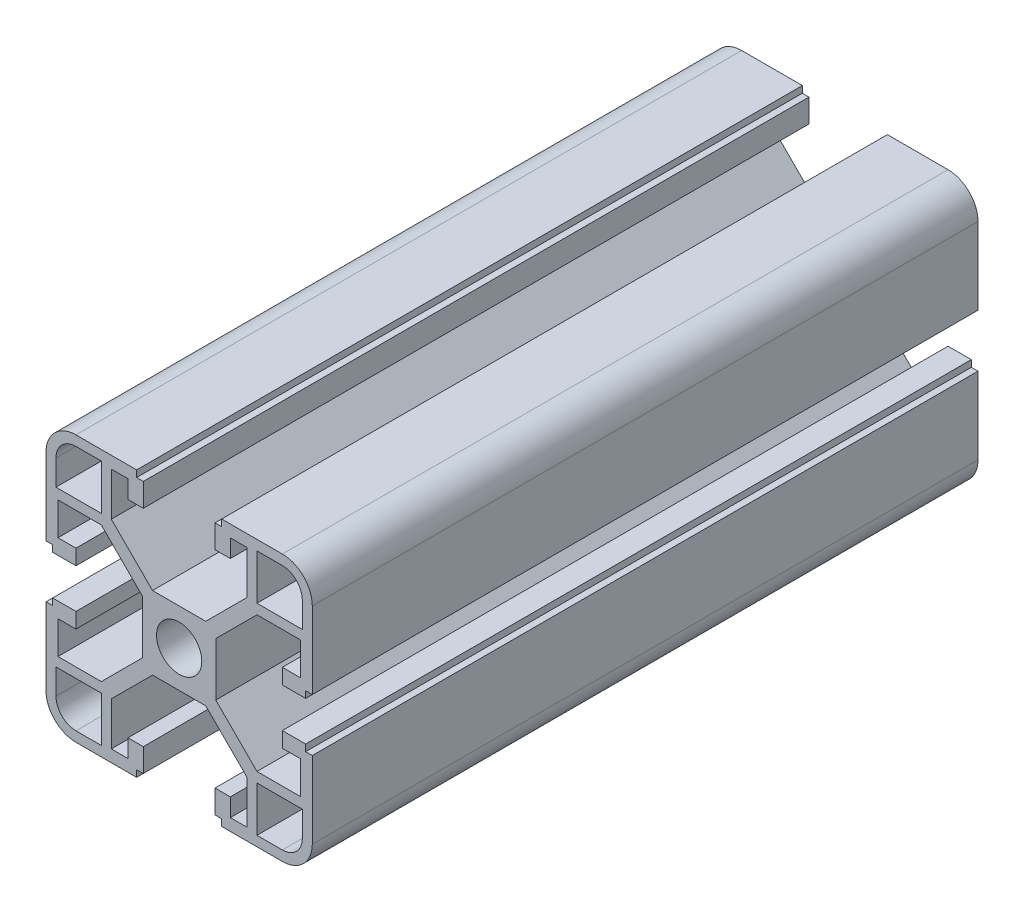
from build123d import *

# Parameters (mm, degrees)
BOSS_EXTRUDE1_DEPTH  = 100
MIRROR3_COPY_1_DEPTH = 100
MIRROR3_COPY_2_DEPTH = 100


with BuildPart() as part:
    # Sketch1 → Boss-Extrude1 (new body)
    with BuildSketch(Plane.XY):
        with BuildLine():
            Line((3.4, 0), (5.5, 0))
            Line((5.5, 0), (5.5, 4))
            Line((5.5, 4), (11.69, 10.19))
            Line((11.69, 10.19), (18.2, 10.19))
            Line((18.2, 10.19), (18.2, 5.265595036))
            Line((18.2, 5.265595036), (15.5, 5.265595036))
            Line((15.5, 5.265595036), (15.5, 2.965595036))
            Line((15.5, 2.965595036), (19, 2.965595036))
            Line((19, 2.965595036), (19, 3.965595036))
            Line((19, 3.965595036), (20, 3.965595036))
            Line((20, 3.965595036), (20, 15.5))
            ThreePointArc((20, 15.5), (18.681980515, 18.681980515), (15.5, 20))
            Line((15.5, 20), (6.385304712, 20))
            Line((6.385304712, 20), (6.385304712, 19))
            Line((6.385304712, 19), (5.385304712, 19))
            Line((5.385304712, 19), (5.385304712, 15.5))
            Line((5.385304712, 15.5), (7.685304712, 15.5))
            Line((7.685304712, 15.5), (7.685304712, 18.2))
            Line((7.685304712, 18.2), (10.19, 18.2))
            Line((10.19, 18.2), (10.19, 11.69))
            Line((10.19, 11.69), (4, 5.5))
            Line((4, 5.5), (0, 5.5))
            Line((0, 5.5), (0, 3.4))
            ThreePointArc((0, 3.4), (2.404163056, 2.404163056), (3.4, 0))
        make_face()
        with BuildLine():
            Line((18.5, 11.69), (18.5, 15.5))
            ThreePointArc((18.5, 15.5), (17.621320344, 17.621320344), (15.5, 18.5))
            Line((15.5, 18.5), (11.69, 18.5))
            Line((11.69, 18.5), (11.69, 11.69))
            Line((11.69, 11.69), (18.5, 11.69))
        make_face(mode=Mode.SUBTRACT)
    boss_extrude1 = extrude(amount=BOSS_EXTRUDE1_DEPTH)

    # Mirror1: Boss-Extrude1 across plane
    add(boss_extrude1.mirror(Plane.ZX))

    # Mirror2: Boss-Extrude1 across plane
    add(boss_extrude1.mirror(Plane(origin=(0, 0, 0), x_dir=(0, 0, 1), z_dir=(1, 0, 0))))

    # Mirror3 copy 1 sketch → Mirror3 copy 1 (add)
    with BuildSketch(Plane(origin=(0, 0, 0), x_dir=(-1, 0, 0), z_dir=(0, 0, 1))):
        with BuildLine():
            Line((3.4, 0), (5.5, 0))
            Line((5.5, 0), (5.5, 4))
            Line((5.5, 4), (11.69, 10.19))
            Line((11.69, 10.19), (18.2, 10.19))
            Line((18.2, 10.19), (18.2, 5.265595036))
            Line((18.2, 5.265595036), (15.5, 5.265595036))
            Line((15.5, 5.265595036), (15.5, 2.965595036))
            Line((15.5, 2.965595036), (19, 2.965595036))
            Line((19, 2.965595036), (19, 3.965595036))
            Line((19, 3.965595036), (20, 3.965595036))
            Line((20, 3.965595036), (20, 15.5))
            ThreePointArc((20, 15.5), (18.681980515, 18.681980515), (15.5, 20))
            Line((15.5, 20), (6.385304712, 20))
            Line((6.385304712, 20), (6.385304712, 19))
            Line((6.385304712, 19), (5.385304712, 19))
            Line((5.385304712, 19), (5.385304712, 15.5))
            Line((5.385304712, 15.5), (7.685304712, 15.5))
            Line((7.685304712, 15.5), (7.685304712, 18.2))
            Line((7.685304712, 18.2), (10.19, 18.2))
            Line((10.19, 18.2), (10.19, 11.69))
            Line((10.19, 11.69), (4, 5.5))
            Line((4, 5.5), (0, 5.5))
            Line((0, 5.5), (0, 3.4))
            ThreePointArc((0, 3.4), (2.404163056, 2.404163056), (3.4, 0))
        make_face()
        with BuildLine():
            Line((18.5, 11.69), (18.5, 15.5))
            ThreePointArc((18.5, 15.5), (17.621320344, 17.621320344), (15.5, 18.5))
            Line((15.5, 18.5), (11.69, 18.5))
            Line((11.69, 18.5), (11.69, 11.69))
            Line((11.69, 11.69), (18.5, 11.69))
        make_face(mode=Mode.SUBTRACT)
    extrude(amount=MIRROR3_COPY_1_DEPTH)

    # Mirror3 copy 2 sketch → Mirror3 copy 2 (add)
    with BuildSketch(Plane.XY):
        with BuildLine():
            Line((3.4, 0), (5.5, 0))
            Line((5.5, 0), (5.5, -4))
            Line((5.5, -4), (11.69, -10.19))
            Line((11.69, -10.19), (18.2, -10.19))
            Line((18.2, -10.19), (18.2, -5.265595036))
            Line((18.2, -5.265595036), (15.5, -5.265595036))
            Line((15.5, -5.265595036), (15.5, -2.965595036))
            Line((15.5, -2.965595036), (19, -2.965595036))
            Line((19, -2.965595036), (19, -3.965595036))
            Line((19, -3.965595036), (20, -3.965595036))
            Line((20, -3.965595036), (20, -15.5))
            ThreePointArc((20, -15.5), (18.681980515, -18.681980515), (15.5, -20))
            Line((15.5, -20), (6.385304712, -20))
            Line((6.385304712, -20), (6.385304712, -19))
            Line((6.385304712, -19), (5.385304712, -19))
            Line((5.385304712, -19), (5.385304712, -15.5))
            Line((5.385304712, -15.5), (7.685304712, -15.5))
            Line((7.685304712, -15.5), (7.685304712, -18.2))
            Line((7.685304712, -18.2), (10.19, -18.2))
            Line((10.19, -18.2), (10.19, -11.69))
            Line((10.19, -11.69), (4, -5.5))
            Line((4, -5.5), (0, -5.5))
            Line((0, -5.5), (0, -3.4))
            ThreePointArc((0, -3.4), (2.404163056, -2.404163056), (3.4, 0))
        make_face()
        with BuildLine():
            Line((18.5, -11.69), (18.5, -15.5))
            ThreePointArc((18.5, -15.5), (17.621320344, -17.621320344), (15.5, -18.5))
            Line((15.5, -18.5), (11.69, -18.5))
            Line((11.69, -18.5), (11.69, -11.69))
            Line((11.69, -11.69), (18.5, -11.69))
        make_face(mode=Mode.SUBTRACT)
    extrude(amount=MIRROR3_COPY_2_DEPTH)


solid = part.part
